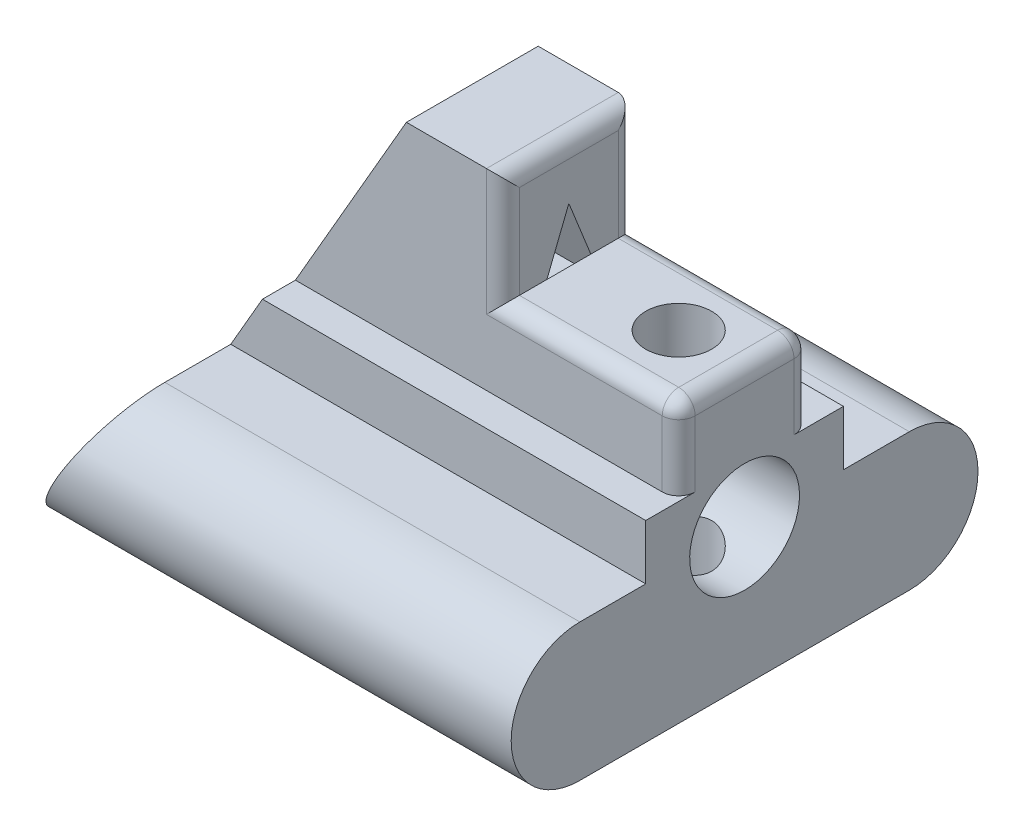
from build123d import *

# Parameters (mm, degrees)
SKETCH1_R               = 10
BOSS_EXTRUDE1_DEPTH     = 90
CUT_EXTRUDE1_DEPTH      = 46
CUT_EXTRUDE1_DEPTH_BACK = 57
SKETCH3_W               = 32
SKETCH3_H               = 24
CUT_EXTRUDE2_DEPTH      = 20
BOSS_EXTRUDE2_DEPTH     = 32
SKETCH5_R               = 6
CUT_EXTRUDE3_DEPTH      = 78
FILLET3_R               = 3


with BuildPart() as part:
    # Sketch1 → Boss-Extrude1 (new body)
    with BuildSketch(Plane(origin=(0, 0, 0), x_dir=(0, 0, -1), z_dir=(1, 0, 0))):
        with BuildLine():
            Line((-30, 0), (30, 0))
            ThreePointArc((30, 0), (42.5, 12.5), (30, 25))
            Line((30, 25), (18, 25))
            Line((18, 25), (18, 35))
            Line((18, 35), (12, 35))
            Line((12, 35), (12, 70))
            Line((12, 70), (-12, 70))
            Line((-12, 70), (-12, 35))
            Line((-12, 35), (-18, 35))
            Line((-18, 35), (-18, 25))
            Line((-18, 25), (-30, 25))
            ThreePointArc((-30, 25), (-42.5, 12.5), (-30, 0))
        make_face()
        with Locations((0, 25)):
            Circle(SKETCH1_R, mode=Mode.SUBTRACT)
        Polygon((-6, 45), (6, 45), (0, 60), align=None, mode=Mode.SUBTRACT)
    extrude(amount=BOSS_EXTRUDE1_DEPTH)

    # Sketch2 → Cut-Extrude1 (cut, two sides)
    with BuildSketch(Plane.XY) as cut_extrude1_sk:
        Polygon((0, 0), (40.414518843, 70), (0, 70), align=None)
    extrude(amount=CUT_EXTRUDE1_DEPTH, mode=Mode.SUBTRACT)
    extrude(cut_extrude1_sk.sketch, amount=-CUT_EXTRUDE1_DEPTH_BACK, mode=Mode.SUBTRACT)

    # Sketch3 → Cut-Extrude2 (cut)
    with BuildSketch(Plane(origin=(0, 70, 0), x_dir=(1, 0, 0), z_dir=(0, 1, 0))):
        with Locations((74, 0)):
            Rectangle(SKETCH3_W, SKETCH3_H)
    extrude(amount=-CUT_EXTRUDE2_DEPTH, mode=Mode.SUBTRACT)

    # Sketch4 → Boss-Extrude2 (add)
    with BuildSketch(Plane(origin=(58, 0, 0), x_dir=(0, 0, -1), z_dir=(1, 0, 0))):
        Polygon((-6, 45), (-4, 50), (4, 50), (6, 45), align=None)
    extrude(amount=BOSS_EXTRUDE2_DEPTH)

    # Sketch5 → Cut-Extrude3 (cut)
    with BuildSketch(Plane(origin=(0, 50, 0), x_dir=(1, 0, 0), z_dir=(0, 1, 0))):
        with Locations((78, 0)):
            Circle(SKETCH5_R)
    extrude(amount=-CUT_EXTRUDE3_DEPTH, mode=Mode.SUBTRACT)

    # Fillet3
    fillet3_edges = [part.edges().sort_by_distance(p)[0] for p in [
        (90, 50, 0),
        (74, 50, 12),
        (58, 60, 12),
        (74, 50, -12),
        (58, 60, -12),
        (58, 70, 0),
        (90, 42.5, -12),
        (90, 42.5, 12),
    ]]
    fillet(fillet3_edges, radius=FILLET3_R)


solid = part.part
